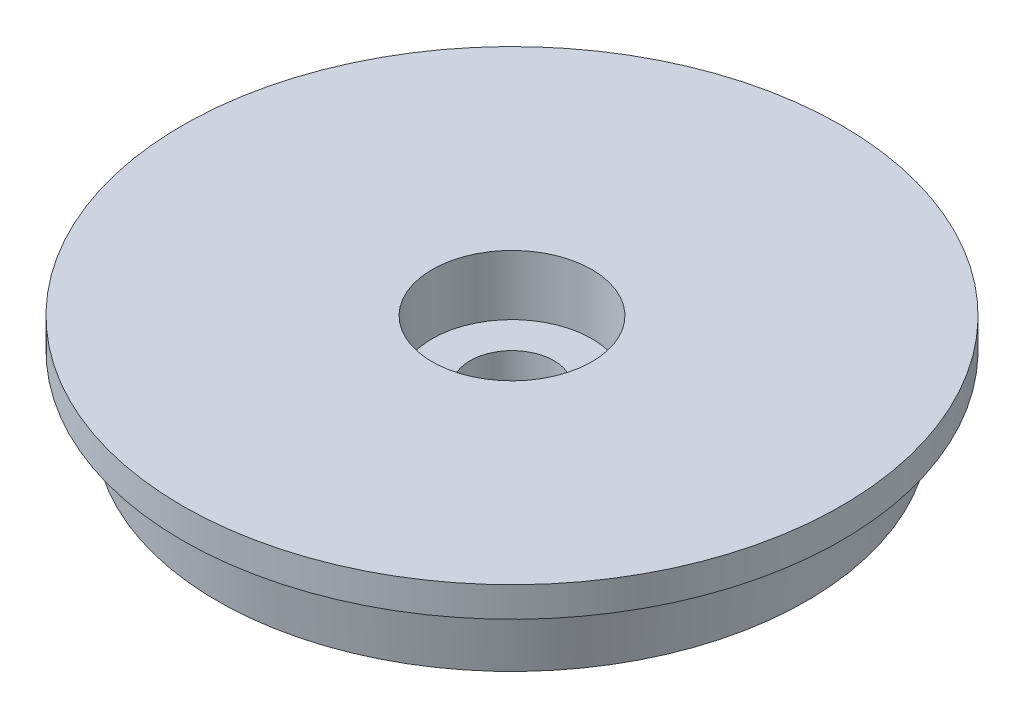
from build123d import *


with BuildPart() as part:
    # Sketch5 → Revolve1 (revolve)
    with BuildSketch(Plane(origin=(0, 0, 0), x_dir=(0, 0, -1), z_dir=(1, 0, 0))):
        Polygon((2.1, 0), (2.1, 2), (4, 2), (4, 5), (16.5, 5), (16.5, 3.5), (15.1, 3.5), (14.75, 0), align=None)
    revolve(axis=Axis((0, 0, 0), (0, 1, 0)))


solid = part.part
